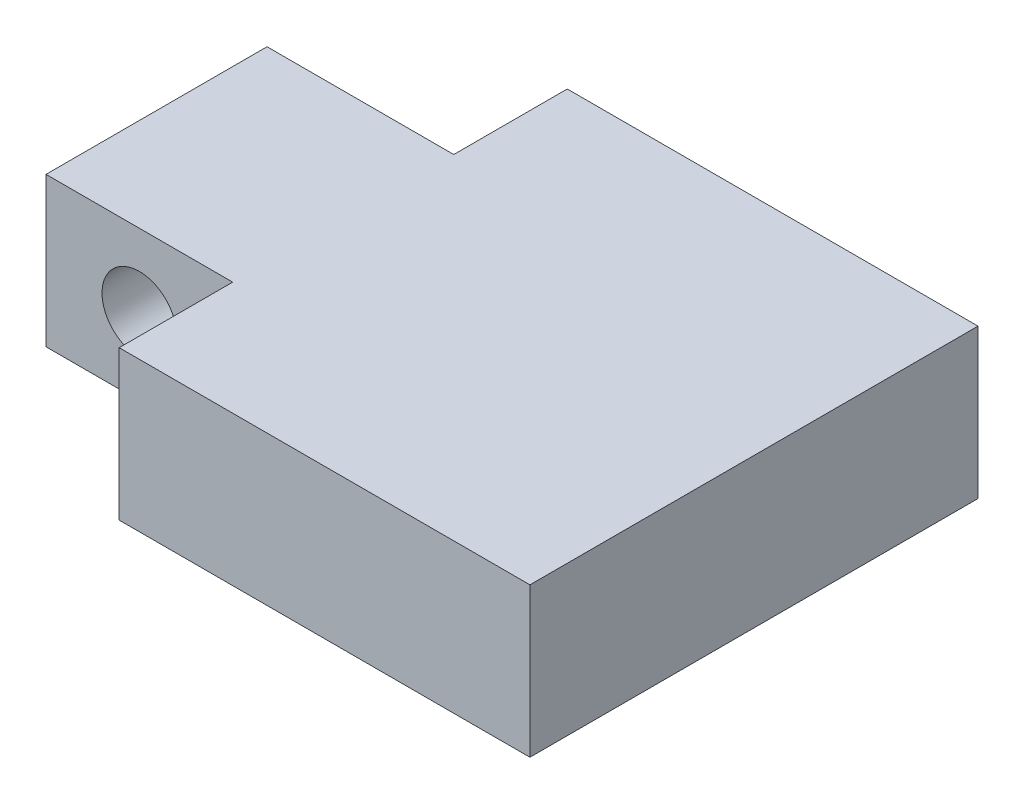
from build123d import *

# Parameters (mm, degrees)
SKETCH1_W           = 101.6
SKETCH1_H           = 76.2
BOSS_EXTRUDE1_DEPTH = 25.4
SKETCH2_W           = 31.75
SKETCH2_H           = 19.304
CUT_EXTRUDE2_DEPTH  = 26.4
SKETCH4_R           = 6.35
CUT_EXTRUDE3_DEPTH  = 57.896


with BuildPart() as part:
    # Sketch1 → Boss-Extrude1 (new body)
    with BuildSketch(Plane(origin=(0, 0, 0), x_dir=(1, 0, 0), z_dir=(0, 1, 0))):
        Rectangle(SKETCH1_W, SKETCH1_H)
    extrude(amount=BOSS_EXTRUDE1_DEPTH)

    # Sketch2 → Cut-Extrude2 (cut, through all)
    with BuildSketch(Plane(origin=(0, 25.4, 0), x_dir=(1, 0, 0), z_dir=(0, 1, 0))):
        with Locations((-34.925, 28.448)):
            Rectangle(SKETCH2_W, SKETCH2_H)
        with Locations((-34.925, -28.448)):
            Rectangle(SKETCH2_W, SKETCH2_H)
    extrude(amount=-CUT_EXTRUDE2_DEPTH, mode=Mode.SUBTRACT)

    # Sketch4 → Cut-Extrude3 (cut, through all)
    with BuildSketch(Plane.XY.offset(18.796)):
        with Locations((-34.925, 12.7)):
            Circle(SKETCH4_R)
    extrude(amount=-CUT_EXTRUDE3_DEPTH, mode=Mode.SUBTRACT)


solid = part.part
